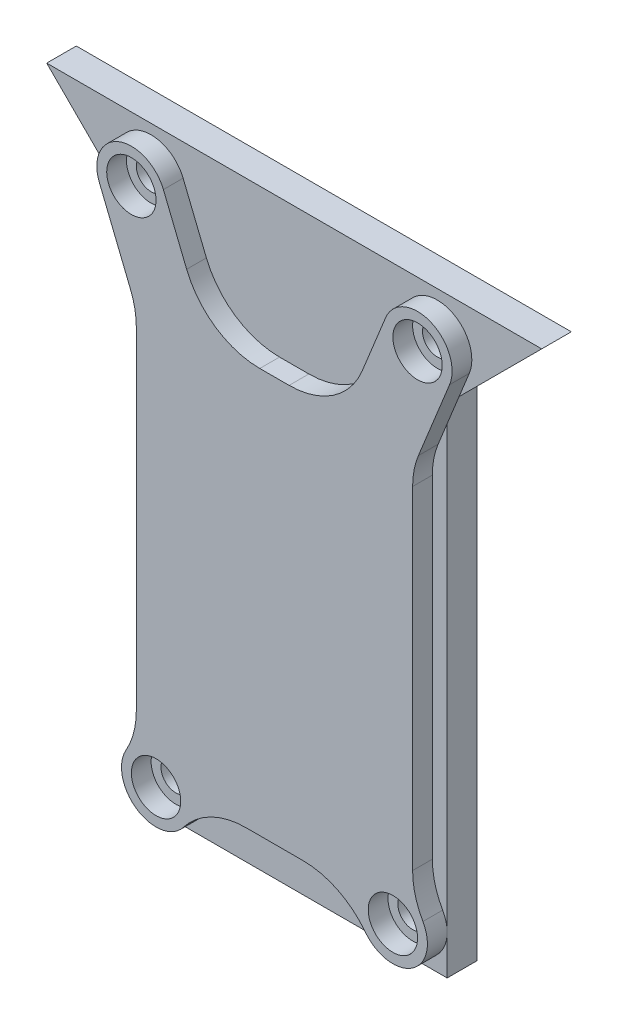
from build123d import *

# Parameters (mm, degrees)
SKETCH1_R           = 1.5
BOSS_EXTRUDE1_DEPTH = 3
SKETCH2_R           = 2.5
BOSS_EXTRUDE2_DEPTH = 2


with BuildPart() as part:
    # Sketch1 → Boss-Extrude1 (new body)
    with BuildSketch(Plane.XY):
        Polygon((0, 0), (31, 0), (31, 50.418881682), (40.581118318, 60), (-9.581118318, 60), (0, 50.418881682), align=None)
        with Locations((30, 55.5)):
            Circle(SKETCH1_R, mode=Mode.SUBTRACT)
        with Locations((27.5, 44)):
            Circle(SKETCH1_R, mode=Mode.SUBTRACT)
        with Locations((27.5, 4)):
            Circle(SKETCH1_R, mode=Mode.SUBTRACT)
        with Locations((3.5, 4)):
            Circle(SKETCH1_R, mode=Mode.SUBTRACT)
        with Locations((3.5, 44)):
            Circle(SKETCH1_R, mode=Mode.SUBTRACT)
        with Locations((1, 55.5)):
            Circle(SKETCH1_R, mode=Mode.SUBTRACT)
    extrude(amount=BOSS_EXTRUDE1_DEPTH)


with BuildPart() as body_2:
    # Sketch2 → Boss-Extrude2 (new body)
    with BuildSketch(Plane.XY.offset(3)):
        with BuildLine():
            Line((14.015011123, 46), (16.984988877, 46))
            ThreePointArc((16.984988877, 46), (21.455677143, 47.365774617), (24.39987727, 50.996763393))
            Line((24.39987727, 50.996763393), (26.755986328, 56.813916016))
            ThreePointArc((26.755986328, 56.813916016), (31.313916016, 58.744013672), (33.244013672, 54.186083984))
            Line((33.244013672, 54.186083984), (30.085111607, 46.386862904))
            ThreePointArc((30.085111607, 46.386862904), (29.647640255, 44.913478063), (29.5, 43.383626297))
            Line((29.5, 43.383626297), (29.5, 9.678908346))
            ThreePointArc((29.5, 9.678908346), (29.765267493, 7.635892672), (30.543478261, 5.72836341))
            ThreePointArc((30.543478261, 5.72836341), (29.433997179, 1.082868719), (24.723086671, 1.869565217))
            ThreePointArc((24.723086671, 1.869565217), (21.914463152, 4.17483525), (18.375856205, 5))
            Line((18.375856205, 5), (12.624143795, 5))
            ThreePointArc((12.624143795, 5), (9.085536848, 4.17483525), (6.276913329, 1.869565217))
            ThreePointArc((6.276913329, 1.869565217), (1.566002821, 1.082868719), (0.456521739, 5.72836341))
            ThreePointArc((0.456521739, 5.72836341), (1.234732507, 7.635892672), (1.5, 9.678908346))
            Line((1.5, 9.678908346), (1.5, 43.383626297))
            ThreePointArc((1.5, 43.383626297), (1.352359745, 44.913478063), (0.914888393, 46.386862904))
            Line((0.914888393, 46.386862904), (-2.244013672, 54.186083984))
            ThreePointArc((-2.244013672, 54.186083984), (-0.313916016, 58.744013672), (4.244013672, 56.813916016))
            Line((4.244013672, 56.813916016), (6.60012273, 50.996763393))
            ThreePointArc((6.60012273, 50.996763393), (9.544322857, 47.365774617), (14.015011123, 46))
        make_face()
        with Locations((27.5, 4)):
            Circle(SKETCH2_R, mode=Mode.SUBTRACT)
        with Locations((30, 55.5)):
            Circle(SKETCH2_R, mode=Mode.SUBTRACT)
        with Locations((1, 55.5)):
            Circle(SKETCH2_R, mode=Mode.SUBTRACT)
        with Locations((3.5, 4)):
            Circle(SKETCH2_R, mode=Mode.SUBTRACT)
    extrude(amount=BOSS_EXTRUDE2_DEPTH)


solid = Compound([part.part, body_2.part])
